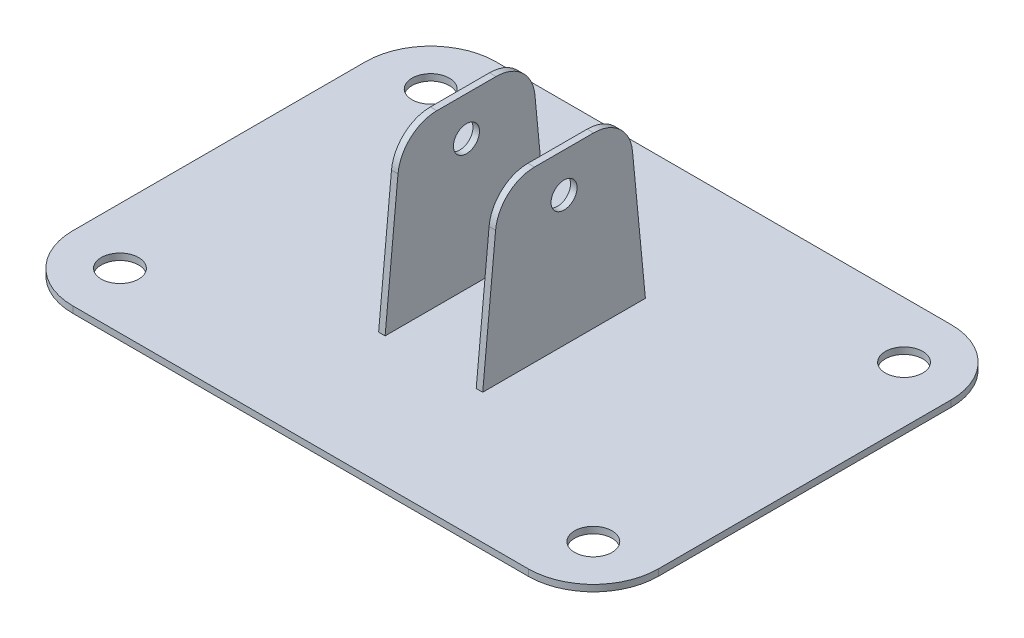
from build123d import *

# Parameters (mm, degrees)
SKETCH1_W            = 90
SKETCH1_H            = 65
SKETCH1_R            = 2.875
BOSS_EXTRUDE1_DEPTH  = 1
FILLET1_R            = 10
BOSS_EXTRUDE2_START  = -37
SKETCH2_R            = 2
BOSS_EXTRUDE2_DEPTH  = 1
FILLET2_R            = 6
FILLET2_OF_MIRROR1_R = 6


with BuildPart() as part:
    # Sketch1 → Boss-Extrude1 (new body)
    with BuildSketch(Plane(origin=(0, 0, 0), x_dir=(1, 0, 0), z_dir=(0, 1, 0))):
        Rectangle(SKETCH1_W, SKETCH1_H)
        with Locations((-36.375, 23.875)):
            Circle(SKETCH1_R, mode=Mode.SUBTRACT)
        with Locations((36.375, 23.875)):
            Circle(SKETCH1_R, mode=Mode.SUBTRACT)
        with Locations((36.375, -23.875)):
            Circle(SKETCH1_R, mode=Mode.SUBTRACT)
        with Locations((-36.375, -23.875)):
            Circle(SKETCH1_R, mode=Mode.SUBTRACT)
    extrude(amount=BOSS_EXTRUDE1_DEPTH)

    # Fillet1
    fillet1_edges = [part.edges().sort_by_distance(p)[0] for p in [
        (45, 0.5, 32.5),
        (-45, 0.5, 32.5),
        (-45, 0.5, -32.5),
        (45, 0.5, -32.5),
    ]]
    fillet(fillet1_edges, radius=FILLET1_R)

    # Sketch2 → Boss-Extrude2 (add)
    with BuildSketch(Plane(origin=(45, 0, 0), x_dir=(0, 0, -1), z_dir=(1, 0, 0)).offset(BOSS_EXTRUDE2_START)):
        Polygon((-12.5, 1), (-10, 27), (10, 27), (12.5, 1), align=None)
        with Locations((0, 21)):
            Circle(SKETCH2_R, mode=Mode.SUBTRACT)
    boss_extrude2 = extrude(amount=-BOSS_EXTRUDE2_DEPTH)

    # Fillet2
    fillet2_edges = [part.edges().sort_by_distance(p)[0] for p in [
        (7.5, 27, 10),
        (7.5, 27, -10),
    ]]
    fillet(fillet2_edges, radius=FILLET2_R)

    # Mirror1: Boss-Extrude2 across plane
    add(boss_extrude2.mirror(Plane.ZY))

    # Fillet2 of Mirror1
    fillet2_of_mirror1_edges = [part.edges().sort_by_distance(p)[0] for p in [
        (-7.5, 27, 10),
        (-7.5, 27, -10),
    ]]
    fillet(fillet2_of_mirror1_edges, radius=FILLET2_OF_MIRROR1_R)


solid = part.part
